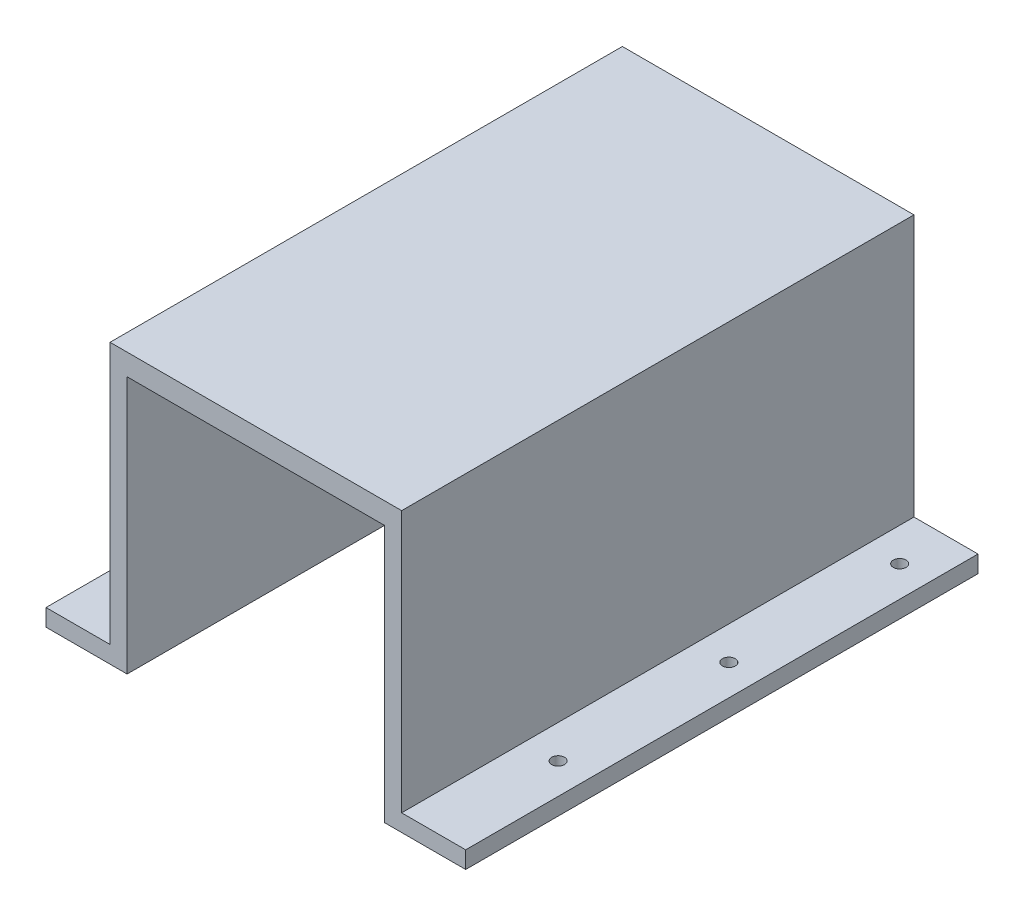
from build123d import *

# Parameters (mm, degrees)
BOSS_EXTRUDE1_DEPTH      = 60
BOSS_EXTRUDE1_DEPTH_BACK = 60
SKETCH2_R                = 1.5
CUT_EXTRUDE1_DEPTH       = 99.860571008


with BuildPart() as part:
    # Sketch1 → Boss-Extrude1 (new, two sides: drawn at the far end of the back side and taken through both)
    with BuildSketch(Plane.XY.offset(-BOSS_EXTRUDE1_DEPTH_BACK)):
        Polygon((-34.15, 4), (-34.15, 65.3), (34.15, 65.3), (34.15, 4), (49.15, 4), (49.15, 0), (34.15, 0), (30.15, 0), (30.15, 60.3), (-30.15, 60.3), (-30.15, 0), (-34.15, 0), (-49.15, 0), (-49.15, 4), align=None)
    extrude(amount=BOSS_EXTRUDE1_DEPTH + BOSS_EXTRUDE1_DEPTH_BACK)

    # Sketch2 → Cut-Extrude1 (cut, through all)
    with BuildSketch(Plane(origin=(0, 4, 0), x_dir=(1, 0, 0), z_dir=(0, 1, 0))):
        with Locations((41.946567631, -31.148436051)):
            Circle(SKETCH2_R)
        with Locations((41.946567631, 8.851563949)):
            Circle(SKETCH2_R)
        with Locations((41.946567631, 48.851563949)):
            Circle(SKETCH2_R)
    cut_extrude1 = extrude(amount=-CUT_EXTRUDE1_DEPTH, mode=Mode.SUBTRACT)

    # Mirror1: Cut-Extrude1 across plane
    add(cut_extrude1.mirror(Plane(origin=(0, 0, 0), x_dir=(0, 0, 1), z_dir=(1, 0, 0))), mode=Mode.SUBTRACT)


solid = part.part
